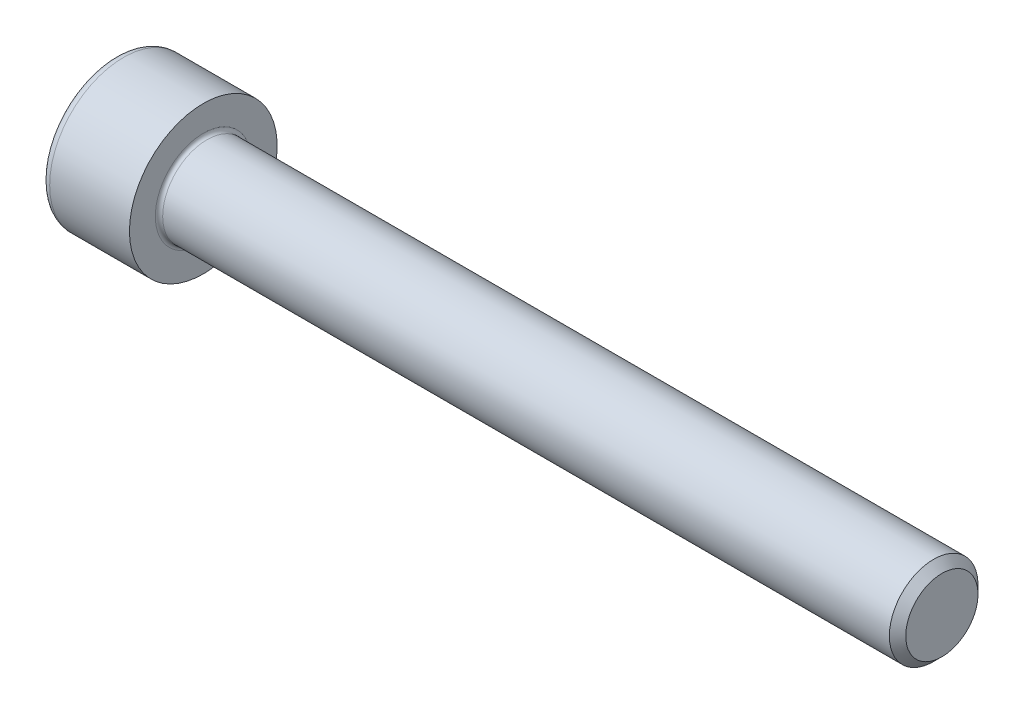
from build123d import *

# Parameters (mm, degrees)
FILLET1_R   = 0.25
FILLET2_R   = 0.6
HEX_2_DEPTH = 3


with BuildPart() as part:
    # BodySke → Base-Revolve (revolve)
    with BuildSketch(Plane.XY):
        Polygon((0, 0), (0, 5), (6, 5), (6, 3), (55.4455, 3), (56, 2.4455), (56, 0), align=None)
    revolve(axis=Axis((-31.75, 0, 0), (1, 0, 0)))

    # Fillet1
    fillet1_edges = [part.edges().sort_by_distance(p)[0] for p in [
        (6, -3, 0),
    ]]
    fillet(fillet1_edges, radius=FILLET1_R)

    # Fillet2
    fillet2_edges = [part.edges().sort_by_distance(p)[0] for p in [
        (0, -5, 0),
    ]]
    fillet(fillet2_edges, radius=FILLET2_R)

    # Sketch2 → Hex-PreBroach (revolve, cut)
    with BuildSketch(Plane.XY):
        Polygon((0, 2.51), (3, 2.51), (4.449149176, 0), (0, 0), align=None)
    revolve(axis=Axis((0, 0, 0), (1, 0, 0)), mode=Mode.SUBTRACT)

    # Sketch3 → Hex 2 (cut)
    with BuildSketch(Plane(origin=(0, 0, 0), x_dir=(0, 0.5, 0.866025404), z_dir=(-1, 0, 0))):
        Polygon((1.449149176, 2.51), (-1.449149176, 2.51), (-2.898298351, 0), (-1.449149176, -2.51), (1.449149176, -2.51), (2.898298351, 0), align=None)
    extrude(amount=-HEX_2_DEPTH, mode=Mode.SUBTRACT)


solid = part.part
